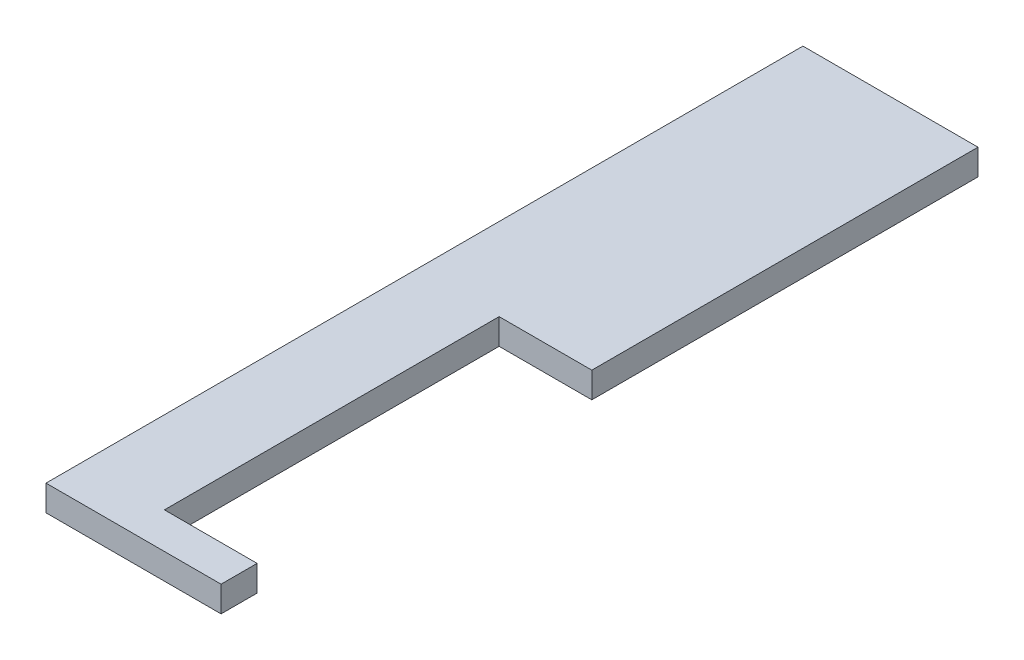
from build123d import *

# Parameters (mm, degrees)
BOSS_EXTRUDE1_DEPTH = 5


with BuildPart() as part:
    # Sketch1 → Boss-Extrude1 (new body)
    with BuildSketch(Plane(origin=(0, 0, 0), x_dir=(1, 0, 0), z_dir=(0, 1, 0))):
        Polygon((0, 0), (0, -147), (34, -147), (34, -140), (16, -140), (16, -75), (34, -75), (34, 0), align=None)
    extrude(amount=BOSS_EXTRUDE1_DEPTH)


solid = part.part
